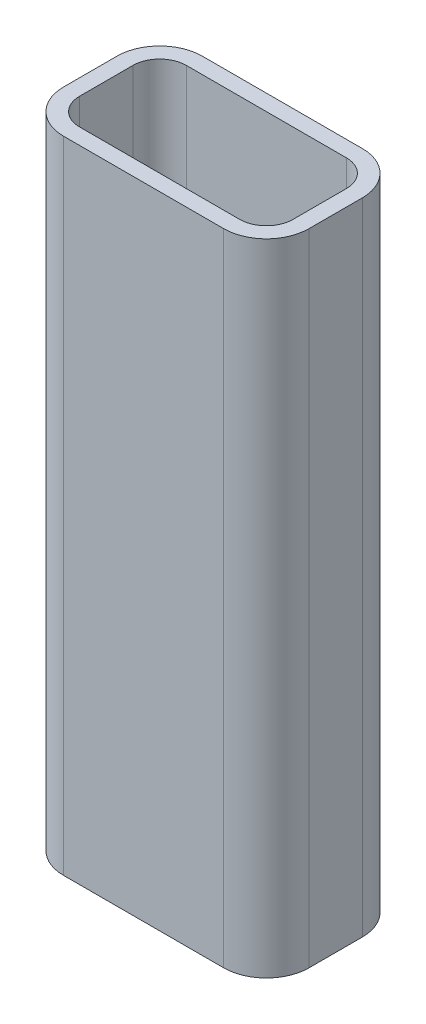
from build123d import *

# Parameters (mm, degrees)
EXTRUDE_THIN2_START = -60
EXTRUDE_THIN2_DEPTH = 120


with BuildPart() as part:
    # Sketch1 → Extrude-Thin2 (new body)
    with BuildSketch(Plane(origin=(0, 0, 0), x_dir=(1, 0, 0), z_dir=(0, 1, 0)).offset(EXTRUDE_THIN2_START)):
        with BuildLine():
            Line((15, 13), (-15, 13))
            ThreePointArc((-15, 13), (-20.656854249, 10.656854249), (-23, 5))
            Line((-23, 5), (-23, -5))
            ThreePointArc((-23, -5), (-20.656854249, -10.656854249), (-15, -13))
            Line((-15, -13), (15, -13))
            ThreePointArc((15, -13), (20.656854249, -10.656854249), (23, -5))
            Line((23, -5), (23, 5))
            ThreePointArc((23, 5), (20.656854249, 10.656854249), (15, 13))
        make_face()
        with BuildLine():
            Line((15, 10), (-15, 10))
            ThreePointArc((-15, 10), (-18.535533906, 8.535533906), (-20, 5))
            Line((-20, 5), (-20, -5))
            ThreePointArc((-20, -5), (-18.535533906, -8.535533906), (-15, -10))
            Line((-15, -10), (15, -10))
            ThreePointArc((15, -10), (18.535533906, -8.535533906), (20, -5))
            Line((20, -5), (20, 5))
            ThreePointArc((20, 5), (18.535533906, 8.535533906), (15, 10))
        make_face(mode=Mode.SUBTRACT)
    extrude(amount=EXTRUDE_THIN2_DEPTH)


solid = part.part
